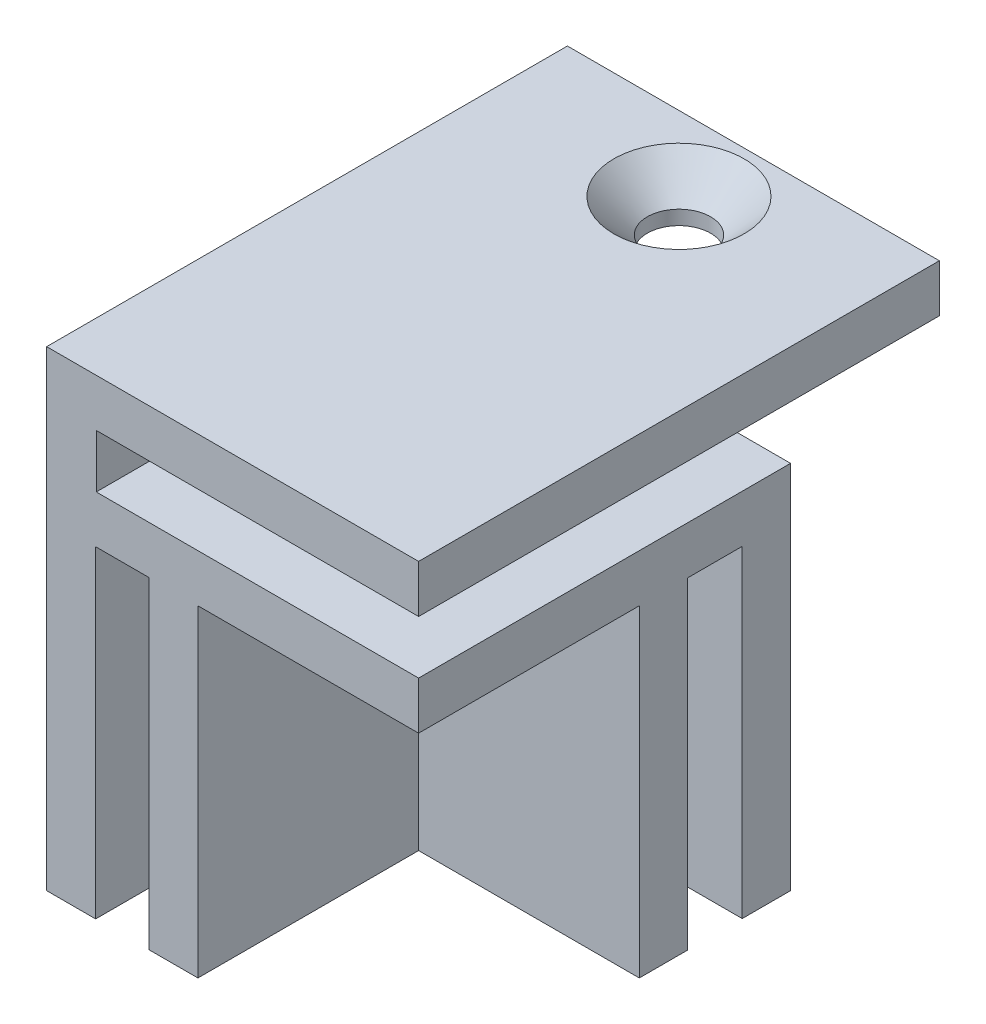
from build123d import *

# Parameters (mm, degrees)
ESQUISSE1_W                                       = 30
ESQUISSE1_H                                       = 30
BOSS_EXTRU_1_DEPTH                                = 38
ESQUISSE2_W                                       = 17.8
ESQUISSE2_H                                       = 4.4
ESQUISSE2_W_2                                     = 4.3
ESQUISSE2_H_2                                     = 17.8
ENL_V_MAT_EXTRU_1_DEPTH                           = 26
ESQUISSE3_W                                       = 26
ESQUISSE3_H                                       = 4.3
ENL_V_MAT_EXTRU_3_DEPTH                           = 31
ESQUISSE4_W                                       = 30
ESQUISSE4_H                                       = 3.85
BOSS_EXTRU_2_DEPTH                                = 12
FRAISAGE_POUR_VIS_T_TE_FRAIS_E_BOMB_E_D           = 5.09999996
FRAISAGE_POUR_VIS_T_TE_FRAIS_E_BOMB_E_CSINK_D     = 10.500000082
FRAISAGE_POUR_VIS_T_TE_FRAIS_E_BOMB_E_CSINK_ANGLE = 90


with BuildPart() as part:
    # Esquisse1 → Boss.-Extru.1 (new body)
    with BuildSketch(Plane(origin=(0, 0, 0), x_dir=(1, 0, 0), z_dir=(0, 1, 0))):
        with Locations((-20.886738322, -1.468531469)):
            Rectangle(ESQUISSE1_W, ESQUISSE1_H)
    extrude(amount=BOSS_EXTRU_1_DEPTH)

    # Esquisse2 → Enlèv. mat.-Extru.1 (cut)
    with BuildSketch(Plane.XZ):
        with Locations((-14.786738322, -7.431468531)):
            Rectangle(ESQUISSE2_W, ESQUISSE2_H)
        with Locations((-29.786738322, 7.568531469)):
            Rectangle(ESQUISSE2_W_2, ESQUISSE2_H_2)
        with Locations((-14.786738322, 7.568531469)):
            Rectangle(ESQUISSE2_W, ESQUISSE2_H_2)
    extrude(amount=-ENL_V_MAT_EXTRU_1_DEPTH, mode=Mode.SUBTRACT)

    # Esquisse3 → Enlèv. mat.-Extru.3 (cut, through all)
    with BuildSketch(Plane.XY.offset(16.468531469)):
        with Locations((-18.886738322, 32)):
            Rectangle(ESQUISSE3_W, ESQUISSE3_H)
    extrude(amount=-ENL_V_MAT_EXTRU_3_DEPTH, mode=Mode.SUBTRACT)

    # Esquisse4 → Boss.-Extru.2 (add)
    with BuildSketch(Plane(origin=(0, 0, -13.531468531), x_dir=(-1, 0, 0), z_dir=(0, 0, -1))):
        with Locations((20.886738322, 36.075)):
            Rectangle(ESQUISSE4_W, ESQUISSE4_H)
    extrude(amount=BOSS_EXTRU_2_DEPTH)

    # Fraisage pour vis à tête fraisée bombée #51 (through all)
    with Locations(Plane(origin=(-20.886738322, 38, -19.531468531), x_dir=(0, 0, 1), z_dir=(0, 1, 0))):
        with Locations((0, 0)):
            CounterSinkHole(FRAISAGE_POUR_VIS_T_TE_FRAIS_E_BOMB_E_D / 2, FRAISAGE_POUR_VIS_T_TE_FRAIS_E_BOMB_E_CSINK_D / 2, counter_sink_angle=FRAISAGE_POUR_VIS_T_TE_FRAIS_E_BOMB_E_CSINK_ANGLE)


solid = part.part
